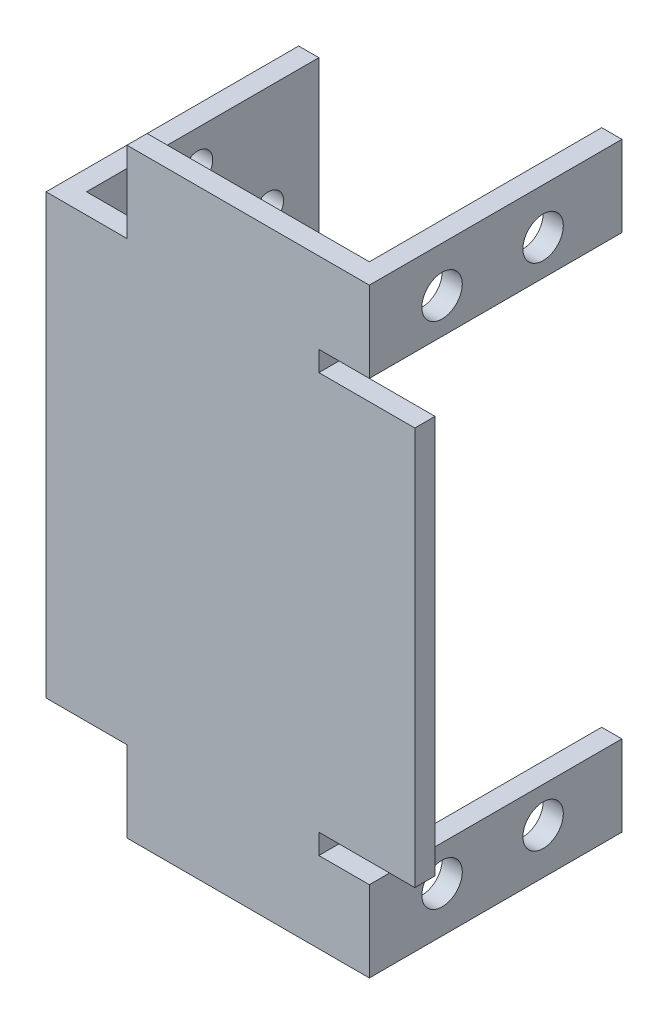
from build123d import *

# Parameters (mm, degrees)
BOSS_EXTRU_1_DEPTH      = 2
ESQUISSE2_W             = 2
ESQUISSE2_H             = 43.4
BOSS_EXTRU_2_DEPTH      = 23
ESQUISSE3_W             = 2
ESQUISSE3_H             = 23
BOSS_EXTRU_3_DEPTH      = 8
ESQUISSE8_W             = 2
ESQUISSE8_H             = 23
BOSS_EXTRU_5_DEPTH      = 8
ESQUISSE9_R             = 2
ENL_V_MAT_EXTRU_3_DEPTH = 2
ESQUISSE10_R            = 1.5
ENL_V_MAT_EXTRU_4_DEPTH = 2


with BuildPart() as part:
    # Esquisse1 → Boss.-Extru.1 (new body)
    with BuildSketch(Plane.XY):
        Polygon((8.75, 17), (8.75, 19), (13.75, 19), (13.75, 27), (-10.25, 27), (-10.25, 19), (-18.25, 19), (-18.25, -24.4), (-10.25, -24.4), (-10.25, -32.4), (13.75, -32.4), (13.75, -24.4), (8.75, -24.4), (8.75, -22.4), (18.25, -22.4), (18.25, 17), align=None)
    extrude(amount=BOSS_EXTRU_1_DEPTH)

    # Esquisse2 → Boss.-Extru.2 (add)
    with BuildSketch(Plane(origin=(0, 0, 0), x_dir=(-1, 0, 0), z_dir=(0, 0, -1))):
        with Locations((17.25, -2.7)):
            Rectangle(ESQUISSE2_W, ESQUISSE2_H)
    extrude(amount=BOSS_EXTRU_2_DEPTH)

    # Esquisse3 → Boss.-Extru.3 (add)
    with BuildSketch(Plane(origin=(0, 27, 0), x_dir=(1, 0, 0), z_dir=(0, 1, 0))):
        with Locations((12.75, 11.5)):
            Rectangle(ESQUISSE3_W, ESQUISSE3_H)
    extrude(amount=-BOSS_EXTRU_3_DEPTH)

    # Esquisse8 → Boss.-Extru.5 (add)
    with BuildSketch(Plane.XZ.offset(32.4)):
        with Locations((12.75, -11.5)):
            Rectangle(ESQUISSE8_W, ESQUISSE8_H)
    extrude(amount=-BOSS_EXTRU_5_DEPTH)

    # Esquisse9 → Enlèv. mat.-Extru.3 (cut)
    with BuildSketch(Plane(origin=(13.75, 0, 0), x_dir=(0, 0, -1), z_dir=(1, 0, 0))):
        with Locations((5.2, 22.5)):
            Circle(ESQUISSE9_R)
        with Locations((15.2, 22.5)):
            Circle(ESQUISSE9_R)
        with Locations((15.2, -27.9)):
            Circle(ESQUISSE9_R)
        with Locations((5.2, -27.9)):
            Circle(ESQUISSE9_R)
    extrude(amount=-ENL_V_MAT_EXTRU_3_DEPTH, mode=Mode.SUBTRACT)

    # Esquisse10 → Enlèv. mat.-Extru.4 (cut)
    with BuildSketch(Plane.ZY.offset(18.25)):
        with Locations((-11, 15.5)):
            Circle(ESQUISSE10_R)
        with Locations((-11, 8.5)):
            Circle(ESQUISSE10_R)
        with Locations((-4, 8.5)):
            Circle(ESQUISSE10_R)
        with Locations((-11, 1.5)):
            Circle(ESQUISSE10_R)
        with Locations((-18, 8.5)):
            Circle(ESQUISSE10_R)
        with Locations((-11, -6.9)):
            Circle(ESQUISSE10_R)
        with Locations((-11, -13.9)):
            Circle(ESQUISSE10_R)
        with Locations((-4, -13.9)):
            Circle(ESQUISSE10_R)
        with Locations((-18, -13.9)):
            Circle(ESQUISSE10_R)
        with Locations((-11, -20.9)):
            Circle(ESQUISSE10_R)
    extrude(amount=-ENL_V_MAT_EXTRU_4_DEPTH, mode=Mode.SUBTRACT)


solid = part.part
